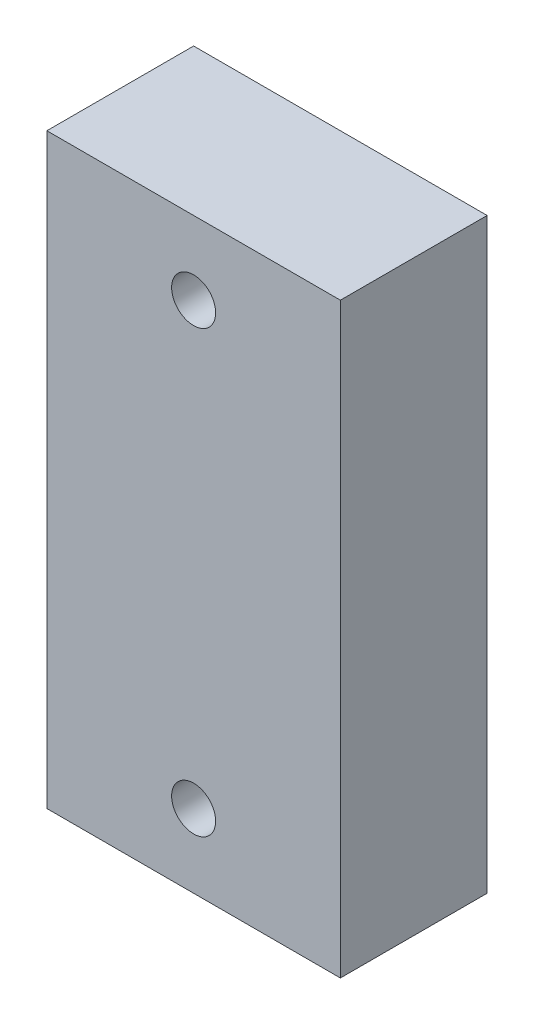
from build123d import *

# Parameters (mm, degrees)
ESQUISSE1_W        = 20
ESQUISSE1_H        = 40
ESQUISSE1_R        = 1.5
BOSS_EXTRU_1_DEPTH = 10


with BuildPart() as part:
    # Esquisse1 → Boss.-Extru.1 (new body)
    with BuildSketch(Plane.XY):
        with Locations((-10, 20)):
            Rectangle(ESQUISSE1_W, ESQUISSE1_H)
        with Locations((-10, 35)):
            Circle(ESQUISSE1_R, mode=Mode.SUBTRACT)
        with Locations((-10, 5)):
            Circle(ESQUISSE1_R, mode=Mode.SUBTRACT)
    extrude(amount=BOSS_EXTRU_1_DEPTH)


solid = part.part
